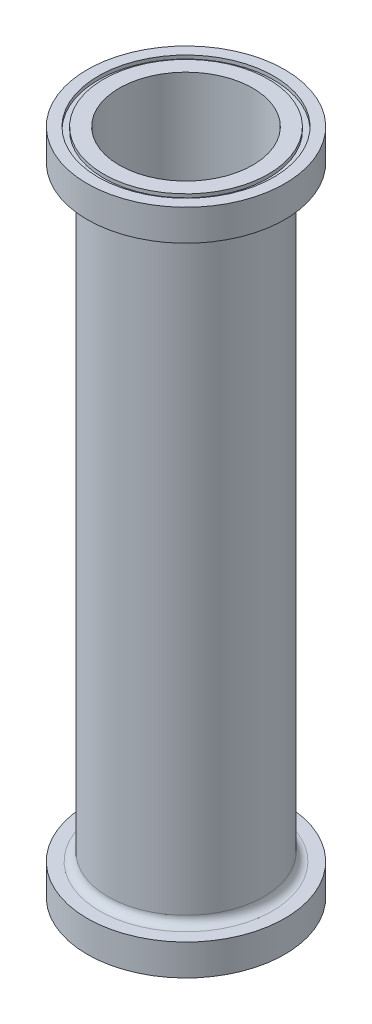
from build123d import *

# Parameters (mm, degrees)
SKETCH2_R            = 44.45
SKETCH2_R_2          = 38.1
BASE_CYLINDER_DEPTH  = 381
SKETCH3_R            = 56.388
SKETCH3_R_2          = 41.275
AFT_FLANGE_DEPTH     = 17.78
FORWARD_START        = -17.78
SKETCH4_R            = 56.388
SKETCH4_R_2          = 41.275
FORWARD_FLANGE_DEPTH = 17.78
SKETCH6_R            = 50.0761
SKETCH6_R_2          = 47.0027
O_RING_SLOT_1_DEPTH  = 1.9812
O_RING_START         = -1.9812
SKETCH7_R            = 50.0761
SKETCH7_R_2          = 47.0027
O_RING_SLOT_2_DEPTH  = 1.9812
FILLET1_R            = 4.7625


with BuildPart() as part:
    # Sketch2 → Base Cylinder (new body)
    with BuildSketch(Plane(origin=(0, 0, 0), x_dir=(1, 0, 0), z_dir=(0, 1, 0))):
        Circle(SKETCH2_R)
        Circle(SKETCH2_R_2, mode=Mode.SUBTRACT)
    extrude(amount=BASE_CYLINDER_DEPTH)

    # Sketch3 → Aft Flange (add)
    with BuildSketch(Plane.XZ):
        Circle(SKETCH3_R)
        Circle(SKETCH3_R_2, mode=Mode.SUBTRACT)
    extrude(amount=-AFT_FLANGE_DEPTH)

    # Sketch4 → Forward Flange (add)
    with BuildSketch(Plane(origin=(0, 381, 0), x_dir=(1, 0, 0), z_dir=(0, 1, 0)).offset(FORWARD_START)):
        Circle(SKETCH4_R)
        Circle(SKETCH4_R_2, mode=Mode.SUBTRACT)
    extrude(amount=FORWARD_FLANGE_DEPTH)

    # Sketch6 → O-Ring Slot 1 (cut)
    with BuildSketch(Plane.XZ):
        Circle(SKETCH6_R)
        Circle(SKETCH6_R_2, mode=Mode.SUBTRACT)
    extrude(amount=-O_RING_SLOT_1_DEPTH, mode=Mode.SUBTRACT)

    # Sketch7 → O-Ring Slot 2 (cut)
    with BuildSketch(Plane(origin=(0, 381, 0), x_dir=(1, 0, 0), z_dir=(0, 1, 0)).offset(O_RING_START)):
        Circle(SKETCH7_R)
        Circle(SKETCH7_R_2, mode=Mode.SUBTRACT)
    extrude(amount=O_RING_SLOT_2_DEPTH, mode=Mode.SUBTRACT)

    # Fillet1
    fillet1_edges = [part.edges().sort_by_distance(p)[0] for p in [
        (-44.45, 17.78, 0),
        (-44.45, 363.22, 0),
    ]]
    fillet(fillet1_edges, radius=FILLET1_R)


solid = part.part
